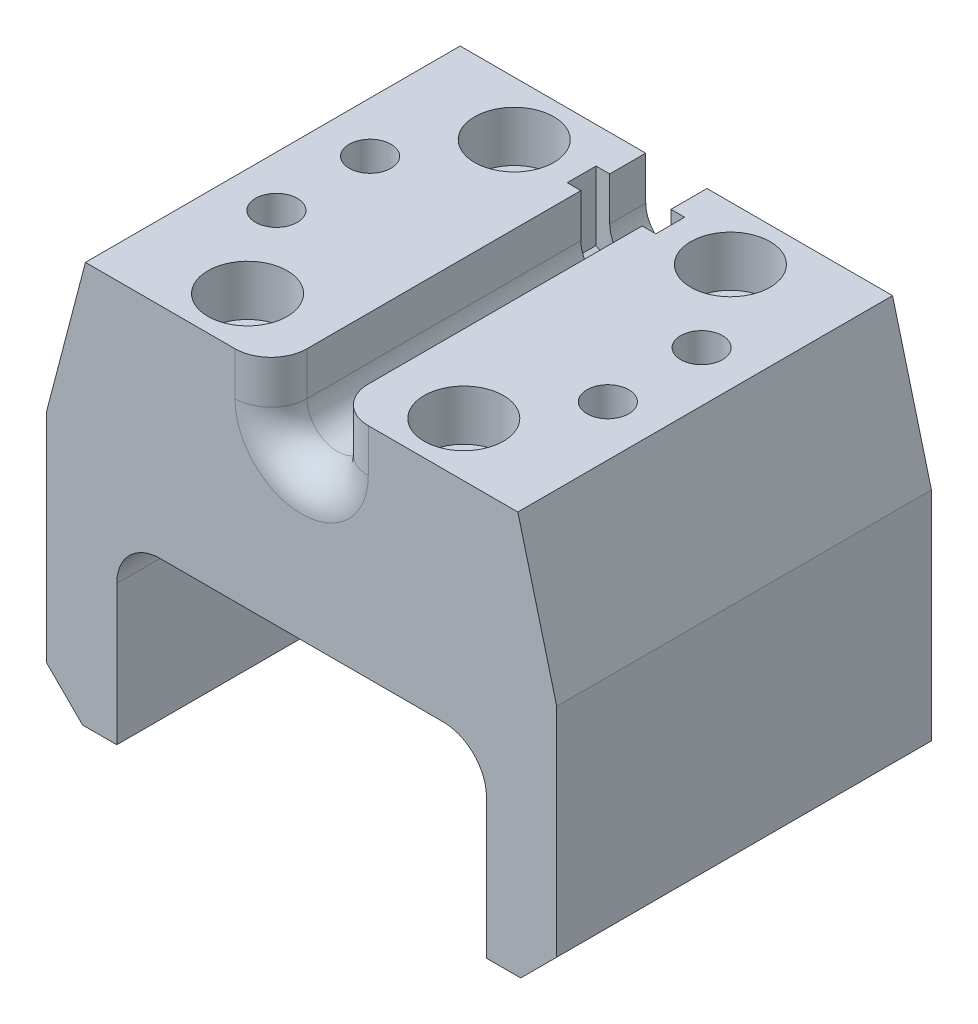
from build123d import *

# Parameters (mm, degrees)
BOSS_EXTRUDE1_DEPTH = 26
CUT_EXTRUDE8_DEPTH  = 53
FILLET1_R           = 6
SKETCH2_R           = 2.9
SKETCH2_R_2         = 3.05
CUT_EXTRUDE1_DEPTH  = 29
SKETCH3_R           = 5.5
CUT_EXTRUDE2_DEPTH  = 7
CHAMFER2_SIZE       = 5
CUT_EXTRUDE9_DEPTH  = 53
CUT_EXTRUDE10_START = -5
CUT_EXTRUDE10_DEPTH = 4
FILLET2_R           = 5
SKETCH12_R          = 3.05
CUT_EXTRUDE11_DEPTH = 4
FILLET3_R           = 2


with BuildPart() as part:
    # Sketch1 → Boss-Extrude1 (new body, symmetric)
    with BuildSketch(Plane.XY):
        Polygon((35.4, 6), (-35.4, 6), (-35.4, -49.8), (-25.65, -49.8), (-25.65, -24.4), (25.65, -24.4), (25.65, -49.8), (35.4, -49.8), align=None)
    extrude(amount=BOSS_EXTRUDE1_DEPTH, both=True)

    # Sketch9 → Cut-Extrude8 (cut, through all)
    with BuildSketch(Plane.XY.offset(26)):
        Polygon((-30, 6), (-35.4, -14.65), (-35.4, 6), align=None)
        Polygon((35.4, 6), (30, 6), (35.4, -14.65), align=None)
    extrude(amount=-CUT_EXTRUDE8_DEPTH, mode=Mode.SUBTRACT)

    # Fillet1
    fillet1_edges = [part.edges().sort_by_distance(p)[0] for p in [
        (25.65, -24.4, 0),
        (-25.65, -24.4, 0),
    ]]
    fillet(fillet1_edges, radius=FILLET1_R)

    # Sketch2 → Cut-Extrude1 (cut)
    with BuildSketch(Plane(origin=(0, 6, 0), x_dir=(1, 0, 0), z_dir=(0, 1, 0))):
        with Locations((-23, 6.5)):
            Circle(SKETCH2_R)
        with Locations((-23, -6.5)):
            Circle(SKETCH2_R)
        with Locations((-15, 18.5)):
            Circle(SKETCH2_R_2)
        with Locations((23, -6.5)):
            Circle(SKETCH2_R)
        with Locations((23, 6.5)):
            Circle(SKETCH2_R)
        with Locations((15, 18.5)):
            Circle(SKETCH2_R_2)
        with Locations((15, -18.5)):
            Circle(SKETCH2_R_2)
        with Locations((-15, -18.5)):
            Circle(SKETCH2_R_2)
    extrude(amount=-CUT_EXTRUDE1_DEPTH, mode=Mode.SUBTRACT)

    # Sketch3 → Cut-Extrude2 (cut)
    with BuildSketch(Plane(origin=(0, 6, 0), x_dir=(1, 0, 0), z_dir=(0, 1, 0))):
        with Locations((-15, 18.5)):
            Circle(SKETCH3_R)
        with Locations((15, 18.5)):
            Circle(SKETCH3_R)
        with Locations((-15, -18.5)):
            Circle(SKETCH3_R)
        with Locations((15, -18.5)):
            Circle(SKETCH3_R)
    extrude(amount=-CUT_EXTRUDE2_DEPTH, mode=Mode.SUBTRACT)

    # Chamfer2
    chamfer2_edges = [part.edges().sort_by_distance(p)[0] for p in [
        (35.4, -49.8, 0),
        (-35.4, -49.8, 0),
    ]]
    chamfer(chamfer2_edges, length=CHAMFER2_SIZE)

    # Sketch10 → Cut-Extrude9 (cut, through all)
    with BuildSketch(Plane(origin=(0, 0, -26), x_dir=(-1, 0, 0), z_dir=(0, 0, -1))):
        with BuildLine():
            Line((-4.25, 0), (-4.25, 11.491510708))
            Line((-4.25, 11.491510708), (4.25, 11.491510708))
            Line((4.25, 11.491510708), (4.25, 0))
            ThreePointArc((4.25, 0), (0, -4.25), (-4.25, 0))
        make_face()
    extrude(amount=-CUT_EXTRUDE9_DEPTH, mode=Mode.SUBTRACT)

    # Sketch11 → Cut-Extrude10 (cut)
    with BuildSketch(Plane(origin=(0, 0, -26), x_dir=(-1, 0, 0), z_dir=(0, 0, -1)).offset(CUT_EXTRUDE10_START)):
        Polygon((-6.15, 3.550704156), (-6.15, 9.910448096), (6.15, 9.910448096), (6.15, 3.550704156), (6.15, -3.550704156), (0, -7.101408311), (-6.15, -3.550704156), align=None)
    extrude(amount=-CUT_EXTRUDE10_DEPTH, mode=Mode.SUBTRACT)

    # Fillet2
    fillet2_edges = [part.edges().sort_by_distance(p)[0] for p in [
        (4.25, 3, 26),
        (-4.25, 3, 26),
        (0, -4.25, 26),
    ]]
    fillet(fillet2_edges, radius=FILLET2_R)

    # Sketch12 → Cut-Extrude11 (cut)
    with BuildSketch(Plane(origin=(0, -23, 0), x_dir=(1, 0, 0), z_dir=(0, 1, 0))):
        with Locations((-15, 18.5)):
            Circle(SKETCH12_R)
        with Locations((15, 18.5)):
            Circle(SKETCH12_R)
        with Locations((15, -18.5)):
            Circle(SKETCH12_R)
        with Locations((-15, -18.5)):
            Circle(SKETCH12_R)
    extrude(amount=-CUT_EXTRUDE11_DEPTH, mode=Mode.SUBTRACT)

    # Fillet3
    fillet3_edges = [part.edges().sort_by_distance(p)[0] for p in [
        (-25.9, -23, -6.5),
        (20.1, -23, -6.5),
        (20.1, -23, 6.5),
        (-25.9, -23, 6.5),
    ]]
    fillet(fillet3_edges, radius=FILLET3_R)


solid = part.part
